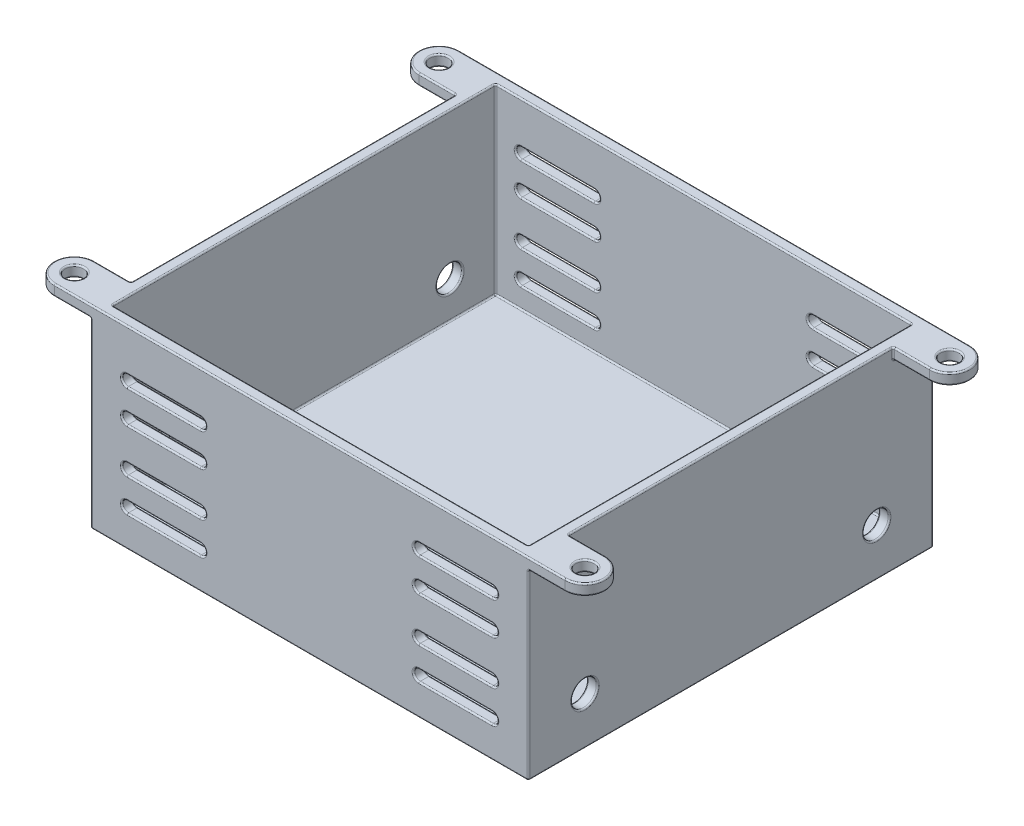
from build123d import *

# Parameters (mm, degrees)
SKETCH2_W               = 60
SKETCH2_H               = 55.5
SKETCH2_W_2             = 57
SKETCH2_H_2             = 52.5
BOSS_EXTRUDE1_DEPTH     = 25
SKETCH3_W               = 60
SKETCH3_H               = 55.5
BOSS_EXTRUDE2_DEPTH     = 1.5
SKETCH4_R               = 1.25
BOSS_EXTRUDE3_DEPTH     = 1.5
CUT_EXTRUDE1_DEPTH      = 28.75
CUT_EXTRUDE1_DEPTH_BACK = 28.75
SKETCH6_R               = 1.75
CUT_EXTRUDE2_DEPTH      = 38.75
CUT_EXTRUDE2_DEPTH_BACK = 38.75
FILLET1_R               = 0.2


with BuildPart() as part:
    # Sketch2 → Boss-Extrude1 (new body)
    with BuildSketch(Plane(origin=(0, 0, 0), x_dir=(1, 0, 0), z_dir=(0, 1, 0))):
        Rectangle(SKETCH2_W, SKETCH2_H)
        Rectangle(SKETCH2_W_2, SKETCH2_H_2, mode=Mode.SUBTRACT)
    extrude(amount=-BOSS_EXTRUDE1_DEPTH)

    # Sketch3 → Boss-Extrude2 (add)
    with BuildSketch(Plane.XZ.offset(25)):
        Rectangle(SKETCH3_W, SKETCH3_H)
    extrude(amount=BOSS_EXTRUDE2_DEPTH)

    # Sketch4 → Boss-Extrude3 (add)
    with BuildSketch(Plane(origin=(0, 0, 0), x_dir=(1, 0, 0), z_dir=(0, 1, 0))):
        with BuildLine():
            Line((-35, -27.75), (-30, -27.75))
            Line((-30, -27.75), (-30, -22.25))
            Line((-30, -22.25), (-35, -22.25))
            ThreePointArc((-35, -22.25), (-37.75, -25), (-35, -27.75))
        make_face()
        with Locations((-35, -25)):
            Circle(SKETCH4_R, mode=Mode.SUBTRACT)
        with BuildLine():
            Line((30, -27.75), (35, -27.75))
            ThreePointArc((35, -27.75), (37.75, -25), (35, -22.25))
            Line((35, -22.25), (30, -22.25))
            Line((30, -22.25), (30, -27.75))
        make_face()
        with Locations((35, -25)):
            Circle(SKETCH4_R, mode=Mode.SUBTRACT)
        with BuildLine():
            Line((-35, 22.25), (-30, 22.25))
            Line((-30, 22.25), (-30, 27.75))
            Line((-30, 27.75), (-35, 27.75))
            ThreePointArc((-35, 27.75), (-37.75, 25), (-35, 22.25))
        make_face()
        with Locations((-35, 25)):
            Circle(SKETCH4_R, mode=Mode.SUBTRACT)
        with BuildLine():
            Line((35, 22.25), (30, 22.25))
            Line((30, 22.25), (30, 27.75))
            Line((30, 27.75), (35, 27.75))
            ThreePointArc((35, 27.75), (37.75, 25), (35, 22.25))
        make_face()
        with Locations((35, 25)):
            Circle(SKETCH4_R, mode=Mode.SUBTRACT)
    extrude(amount=-BOSS_EXTRUDE3_DEPTH)

    # Sketch5 → Cut-Extrude1 (cut, two sides)
    with BuildSketch(Plane.XY) as cut_extrude1_sk:
        with BuildLine():
            Line((-25, -5.75), (-15, -5.75))
            ThreePointArc((-15, -5.75), (-14.25, -6.5), (-15, -7.25))
            Line((-15, -7.25), (-25, -7.25))
            ThreePointArc((-25, -7.25), (-25.75, -6.5), (-25, -5.75))
        make_face()
        with BuildLine():
            Line((-25, -10.25), (-15, -10.25))
            ThreePointArc((-15, -10.25), (-14.25, -11), (-15, -11.75))
            Line((-15, -11.75), (-25, -11.75))
            ThreePointArc((-25, -11.75), (-25.75, -11), (-25, -10.25))
        make_face()
        with BuildLine():
            Line((-25, -22.25), (-15, -22.25))
            ThreePointArc((-15, -22.25), (-14.25, -21.5), (-15, -20.75))
            Line((-15, -20.75), (-25, -20.75))
            ThreePointArc((-25, -20.75), (-25.75, -21.5), (-25, -22.25))
        make_face()
        with BuildLine():
            Line((-25, -17.75), (-15, -17.75))
            ThreePointArc((-15, -17.75), (-14.25, -17), (-15, -16.25))
            Line((-15, -16.25), (-25, -16.25))
            ThreePointArc((-25, -16.25), (-25.75, -17), (-25, -17.75))
        make_face()
        with BuildLine():
            Line((25, -5.75), (15, -5.75))
            ThreePointArc((15, -5.75), (14.25, -6.5), (15, -7.25))
            Line((15, -7.25), (25, -7.25))
            ThreePointArc((25, -7.25), (25.75, -6.5), (25, -5.75))
        make_face()
        with BuildLine():
            Line((25, -10.25), (15, -10.25))
            ThreePointArc((15, -10.25), (14.25, -11), (15, -11.75))
            Line((15, -11.75), (25, -11.75))
            ThreePointArc((25, -11.75), (25.75, -11), (25, -10.25))
        make_face()
        with BuildLine():
            Line((25, -22.25), (15, -22.25))
            ThreePointArc((15, -22.25), (14.25, -21.5), (15, -20.75))
            Line((15, -20.75), (25, -20.75))
            ThreePointArc((25, -20.75), (25.75, -21.5), (25, -22.25))
        make_face()
        with BuildLine():
            Line((25, -17.75), (15, -17.75))
            ThreePointArc((15, -17.75), (14.25, -17), (15, -16.25))
            Line((15, -16.25), (25, -16.25))
            ThreePointArc((25, -16.25), (25.75, -17), (25, -17.75))
        make_face()
    extrude(amount=CUT_EXTRUDE1_DEPTH, mode=Mode.SUBTRACT)
    extrude(cut_extrude1_sk.sketch, amount=-CUT_EXTRUDE1_DEPTH_BACK, mode=Mode.SUBTRACT)

    # Sketch6 → Cut-Extrude2 (cut, two sides)
    with BuildSketch(Plane(origin=(0, 0, 0), x_dir=(0, 0, -1), z_dir=(1, 0, 0))) as cut_extrude2_sk:
        with Locations((-20, -20)):
            Circle(SKETCH6_R)
        with Locations((20, -20)):
            Circle(SKETCH6_R)
    extrude(amount=CUT_EXTRUDE2_DEPTH, mode=Mode.SUBTRACT)
    extrude(cut_extrude2_sk.sketch, amount=-CUT_EXTRUDE2_DEPTH_BACK, mode=Mode.SUBTRACT)

    # Fillet1
    fillet1_edges = [part.edges().sort_by_distance(p)[0] for p in [
        (14.25, -11, 26.25),
        (20, -11.75, 26.25),
        (25.75, -11, 26.25),
        (20, -20.75, 26.25),
        (14.25, -21.5, 26.25),
        (20, -22.25, 26.25),
        (25.75, -21.5, 26.25),
        (20, -16.25, 26.25),
        (14.25, -17, 26.25),
        (20, -17.75, 26.25),
        (25.75, -17, 26.25),
        (-20, -11.75, 26.25),
        (-14.25, -11, 26.25),
        (-20, -10.25, 26.25),
        (-25.75, -11, 26.25),
        (-20, -22.25, 26.25),
        (-14.25, -21.5, 26.25),
        (-20, -20.75, 26.25),
        (-25.75, -21.5, 26.25),
        (-20, -17.75, 26.25),
        (-14.25, -17, 26.25),
        (-20, -16.25, 26.25),
        (-25.75, -17, 26.25),
        (20, -5.75, 26.25),
        (14.25, -6.5, 26.25),
        (20, -7.25, 26.25),
        (25.75, -6.5, 26.25),
        (0, -25, -26.25),
        (-28.5, -12.5, -26.25),
        (28.5, -25, 0),
        (28.5, -12.5, -26.25),
        (0, -25, 26.25),
        (28.5, -12.5, 26.25),
        (-28.5, -25, 0),
        (-28.5, -12.5, 26.25),
        (25.75, -6.5, -26.25),
        (25.75, -6.5, -27.75),
        (20, -7.25, -26.25),
        (20, -7.25, -27.75),
        (0, 0, -26.25),
        (14.25, -6.5, -26.25),
        (14.25, -6.5, -27.75),
        (20, -5.75, -26.25),
        (20, -5.75, -27.75),
        (25.75, -6.5, 27.75),
        (20, -5.75, 27.75),
        (14.25, -6.5, 27.75),
        (-28.5, 0, 0),
        (20, -7.25, 27.75),
        (0, 0, 26.25),
        (28.5, 0, 0),
        (-25.75, -17, -26.25),
        (-25.75, -17, -27.75),
        (-20, -16.25, -26.25),
        (-20, -16.25, -27.75),
        (-14.25, -17, -26.25),
        (-14.25, -17, -27.75),
        (-20, -17.75, -26.25),
        (-20, -17.75, -27.75),
        (-25.75, -17, 27.75),
        (-20, -17.75, 27.75),
        (-14.25, -17, 27.75),
        (-20, -16.25, 27.75),
        (-25.75, -21.5, -26.25),
        (-25.75, -21.5, -27.75),
        (-20, -20.75, -26.25),
        (-20, -20.75, -27.75),
        (-14.25, -21.5, -26.25),
        (-14.25, -21.5, -27.75),
        (-20, -22.25, -26.25),
        (-20, -22.25, -27.75),
        (-25.75, -21.5, 27.75),
        (-20, -22.25, 27.75),
        (-14.25, -21.5, 27.75),
        (-20, -20.75, 27.75),
        (-25.75, -11, -26.25),
        (-25.75, -11, -27.75),
        (-20, -10.25, -26.25),
        (-20, -10.25, -27.75),
        (-14.25, -11, -26.25),
        (-14.25, -11, -27.75),
        (-20, -11.75, -26.25),
        (-20, -11.75, -27.75),
        (-25.75, -11, 27.75),
        (-20, -11.75, 27.75),
        (-14.25, -11, 27.75),
        (-20, -10.25, 27.75),
        (25.75, -17, -26.25),
        (25.75, -17, -27.75),
        (20, -17.75, -26.25),
        (20, -17.75, -27.75),
        (14.25, -17, -26.25),
        (14.25, -17, -27.75),
        (20, -16.25, -26.25),
        (20, -16.25, -27.75),
        (25.75, -17, 27.75),
        (20, -16.25, 27.75),
        (14.25, -17, 27.75),
        (20, -17.75, 27.75),
        (25.75, -21.5, -26.25),
        (25.75, -21.5, -27.75),
        (20, -22.25, -26.25),
        (20, -22.25, -27.75),
        (14.25, -21.5, -26.25),
        (14.25, -21.5, -27.75),
        (20, -20.75, -26.25),
        (20, -20.75, -27.75),
        (25.75, -21.5, 27.75),
        (20, -20.75, 27.75),
        (14.25, -21.5, 27.75),
        (20, -22.25, 27.75),
        (25.75, -11, -26.25),
        (25.75, -11, -27.75),
        (20, -11.75, -26.25),
        (20, -11.75, -27.75),
        (14.25, -11, -26.25),
        (14.25, -11, -27.75),
        (20, -10.25, -26.25),
        (20, -10.25, -27.75),
        (25.75, -11, 27.75),
        (20, -10.25, 27.75),
        (14.25, -11, 27.75),
        (20, -11.75, 27.75),
        (-25.75, -6.5, -26.25),
        (-25.75, -6.5, -27.75),
        (-20, -5.75, -26.25),
        (-20, -5.75, -27.75),
        (-14.25, -6.5, -26.25),
        (-14.25, -6.5, -27.75),
        (-20, -7.25, -26.25),
        (-20, -7.25, -27.75),
        (-25.75, -6.5, 27.75),
        (-20, -7.25, 27.75),
        (-14.25, -6.5, 27.75),
        (-20, -5.75, 27.75),
        (30, -26.5, 0),
        (0, -26.5, 27.75),
        (-30, -26.5, 0),
        (0, -26.5, -27.75),
        (-30, -20, 21.75),
        (30, -20, 21.75),
        (28.5, -20, 21.75),
        (-28.5, -20, 21.75),
        (-30, -20, -18.25),
        (30, -20, -18.25),
        (28.5, -20, -18.25),
        (-28.5, -20, -18.25),
        (-37.75, -1.5, 25),
        (-32.5, -1.5, 22.25),
        (-30, -1.5, 25),
        (-30, -0.75, 22.25),
        (-32.5, -1.5, 27.75),
        (-36.25, -1.5, 25),
        (-37.75, 0, 25),
        (-32.5, 0, 22.25),
        (-36.25, 0, 25),
        (0, 0, 27.75),
        (30, 0, 0),
        (30, -1.5, 25),
        (32.5, -1.5, 22.25),
        (0, 0, -27.75),
        (30, -0.75, 22.25),
        (37.75, -1.5, 25),
        (32.5, -1.5, 27.75),
        (33.75, -1.5, 25),
        (37.75, 0, 25),
        (32.5, 0, 22.25),
        (33.75, 0, 25),
        (-30, 0, 0),
        (-37.75, -1.5, -25),
        (-32.5, -1.5, -27.75),
        (-30, -1.5, -25),
        (-32.5, -1.5, -22.25),
        (-30, -0.75, -22.25),
        (-36.25, -1.5, -25),
        (-37.75, 0, -25),
        (-32.5, 0, -22.25),
        (-36.25, 0, -25),
        (30, -14, -27.75),
        (30, -14, 27.75),
        (-30, -14, 27.75),
        (-30, -14, -27.75),
        (37.75, -1.5, -25),
        (32.5, -1.5, -22.25),
        (30, -1.5, -25),
        (30, -0.75, -22.25),
        (32.5, -1.5, -27.75),
        (33.75, -1.5, -25),
        (37.75, 0, -25),
        (32.5, 0, -22.25),
        (33.75, 0, -25),
        (-20, -7.25, 26.25),
        (-14.25, -6.5, 26.25),
        (-20, -5.75, 26.25),
        (-25.75, -6.5, 26.25),
        (20, -10.25, 26.25),
    ]]
    fillet(fillet1_edges, radius=FILLET1_R)


solid = part.part
